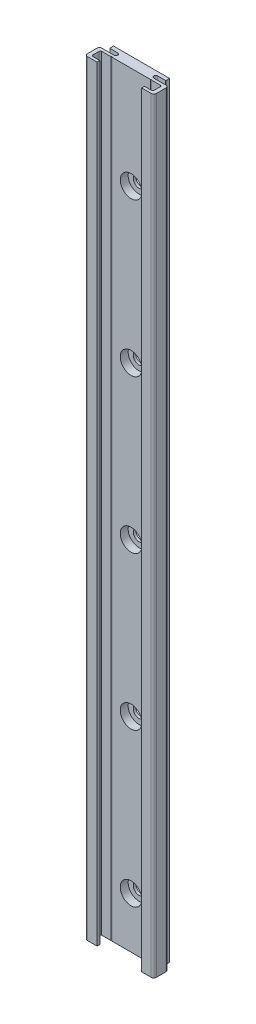
from build123d import *

# Parameters (mm, degrees)
BOSS_EXTRUDE1_DEPTH                              = 300
CUT_EXTRUDE1_DEPTH                               = 301
F_0_4_0_4_DIAMETER_HOLE1_D                       = 0.4
F_0_4_0_4_DIAMETER_HOLE1_DEPTH                   = 300
CBORE_FOR_M4_HEX_HEAD_MACHINE_SCREW1_D           = 4.5
CBORE_FOR_M4_HEX_HEAD_MACHINE_SCREW1_DEPTH       = 4.1
CBORE_FOR_M4_HEX_HEAD_MACHINE_SCREW1_CBORE_D     = 8.5
CBORE_FOR_M4_HEX_HEAD_MACHINE_SCREW1_CBORE_DEPTH = 3.1
FILLET1_R                                        = 0.2
FILLET2_R                                        = 0.5
FILLET3_R                                        = 1


with BuildPart() as part:
    # Sketch1 → Boss-Extrude1 (new body)
    with BuildSketch(Plane(origin=(0, 300, 0), x_dir=(1, 0, 0), z_dir=(0, 1, 0))):
        with BuildLine():
            Line((-13.5, -3), (-13.5, -8.7))
            Line((-13.5, -8.7), (13.5, -8.7))
            Line((13.5, -8.7), (13.5, -3))
            Line((13.5, -3), (7.8, -3))
            ThreePointArc((7.8, -3), (7.05, -2.25), (7.8, -1.5))
            Line((7.8, -1.5), (11, -1.5))
            Line((11, -1.5), (11, 0))
            Line((11, 0), (-11, 0))
            Line((-11, 0), (-11, -1.5))
            Line((-11, -1.5), (-7.8, -1.5))
            ThreePointArc((-7.8, -1.5), (-7.05, -2.25), (-7.8, -3))
            Line((-7.8, -3), (-13.5, -3))
        make_face()
    extrude(amount=-BOSS_EXTRUDE1_DEPTH)

    # Sketch2 → Cut-Extrude1 (cut, through all)
    with BuildSketch(Plane.XZ):
        Polygon((8.75, 8.7), (-8.75, 8.7), (-8.75, 7.6), (-12, 7.6), (-12, 4.1), (12, 4.1), (12, 7.6), (8.75, 7.6), align=None)
    extrude(amount=-CUT_EXTRUDE1_DEPTH, mode=Mode.SUBTRACT)

    # Ø0.4 (0.4) Diameter Hole1
    with Locations(Plane(origin=(0, 300, 0), x_dir=(1, 0, 0), z_dir=(0, 1, 0))):
        with Locations((-7.75, -4.1), (7.75, -4.1)):
            Hole(F_0_4_0_4_DIAMETER_HOLE1_D / 2, depth=F_0_4_0_4_DIAMETER_HOLE1_DEPTH)

    # CBORE for M4 Hex Head Machine Screw1
    with Locations(Plane.XY.offset(4.1)):
        with Locations((0, 260), (0, 200), (0, 140), (0, 80), (0, 20)):
            CounterBoreHole(CBORE_FOR_M4_HEX_HEAD_MACHINE_SCREW1_D / 2, CBORE_FOR_M4_HEX_HEAD_MACHINE_SCREW1_CBORE_D / 2, CBORE_FOR_M4_HEX_HEAD_MACHINE_SCREW1_CBORE_DEPTH, depth=CBORE_FOR_M4_HEX_HEAD_MACHINE_SCREW1_DEPTH)

    # Fillet1
    fillet1_edges = [part.edges().sort_by_distance(p)[0] for p in [
        (-11, 150, 1.5),
        (11, 150, 1.5),
    ]]
    fillet(fillet1_edges, radius=FILLET1_R)

    # Fillet2
    fillet2_edges = [part.edges().sort_by_distance(p)[0] for p in [
        (12, 150, 7.6),
        (12, 150, 4.1),
        (-12, 150, 4.1),
        (-12, 150, 7.6),
    ]]
    fillet(fillet2_edges, radius=FILLET2_R)

    # Fillet3
    fillet3_edges = [part.edges().sort_by_distance(p)[0] for p in [
        (13.5, 150, 3),
        (13.5, 150, 8.7),
        (-13.5, 150, 8.7),
        (-13.5, 150, 3),
    ]]
    fillet(fillet3_edges, radius=FILLET3_R)


solid = part.part
